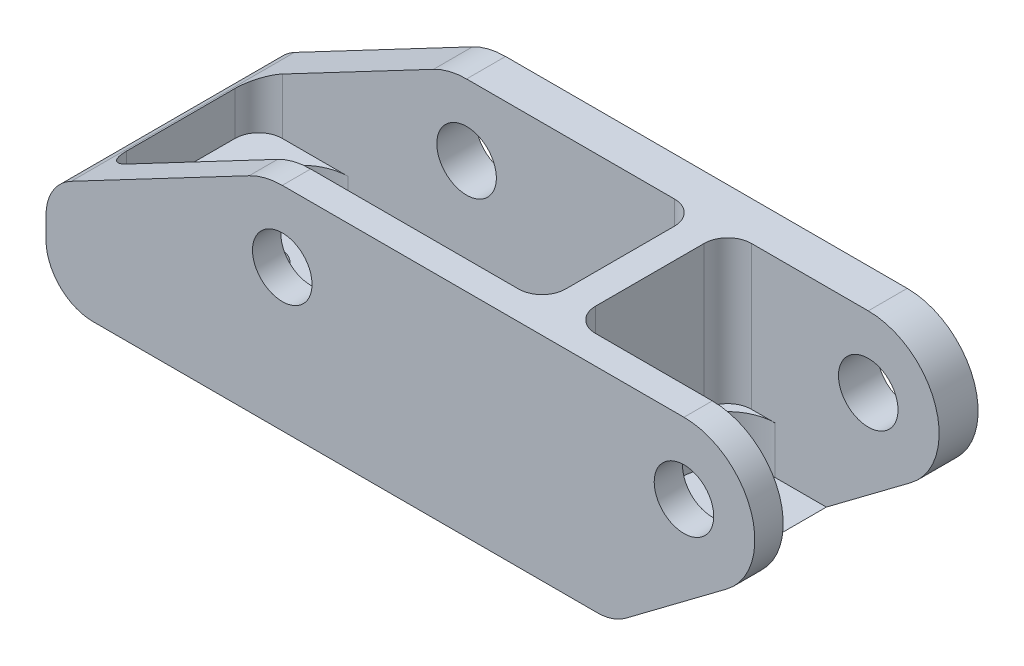
from build123d import *

# Parameters (mm, degrees)
SKETCH1_R           = 3.149606299
BOSS_EXTRUDE1_DEPTH = 28.575
CUT_EXTRUDE1_DEPTH  = 19.304
CUT_EXTRUDE7_DEPTH  = 6.35
SKETCH5_R           = 4
CUT_EXTRUDE3_DEPTH  = 31


with BuildPart() as part:
    # Sketch1 → Boss-Extrude1 (new body)
    with BuildSketch(Plane(origin=(0, 0, 0), x_dir=(1, 0, 0), z_dir=(0, 1, 0))):
        Polygon((0, 6.666666667), (0, 23.333333333), (0, 30), (6.666666667, 30), (93.333333333, 30), (100, 30), (100, 0), (93.333333333, 0), (6.666666667, 0), (0, 0), align=None)
        with Locations((13.333333333, 15)):
            Circle(SKETCH1_R, mode=Mode.SUBTRACT)
        with Locations((53.333333333, 15)):
            Circle(SKETCH1_R, mode=Mode.SUBTRACT)
    extrude(amount=-BOSS_EXTRUDE1_DEPTH)

    # Sketch2 → Cut-Extrude1 (cut)
    with BuildSketch(Plane(origin=(0, 0, 0), x_dir=(1, 0, 0), z_dir=(0, 1, 0))):
        with BuildLine():
            Line((3.810000003, 6.985), (3.810000003, 21.59))
            ThreePointArc((3.810000003, 21.59), (4.739935973, 23.83506403), (6.985000003, 24.765))
            Line((6.985000003, 24.765), (59.678333333, 24.765))
            ThreePointArc((59.678333333, 24.765), (61.923397364, 23.83506403), (62.853333333, 21.59))
            Line((62.853333333, 21.59), (62.853333333, 6.985))
            ThreePointArc((62.853333333, 6.985), (61.923397364, 4.73993597), (59.678333333, 3.81))
            Line((59.678333333, 3.81), (6.985000003, 3.81))
            ThreePointArc((6.985000003, 3.81), (4.739935973, 4.73993597), (3.810000003, 6.985))
        make_face()
        with BuildLine():
            Line((66.853333333, 6.985), (66.853333333, 21.59))
            ThreePointArc((66.853333333, 21.59), (67.783269303, 23.83506403), (70.028333333, 24.765))
            Line((70.028333333, 24.765), (95.25, 24.765))
            Line((95.25, 24.765), (95.25, 3.81))
            Line((95.25, 3.81), (70.028333333, 3.81))
            ThreePointArc((70.028333333, 3.81), (67.783269303, 4.73993597), (66.853333333, 6.985))
        make_face()
    extrude(amount=-CUT_EXTRUDE1_DEPTH, mode=Mode.SUBTRACT)

    # Sketch9 → Cut-Extrude7 (cut)
    with BuildSketch(Plane(origin=(0, -19.304, 0), x_dir=(1, 0, 0), z_dir=(0, 1, 0))):
        with BuildLine():
            Line((7.649092718, 18.135984848), (10.793997252, 22.263484848))
            ThreePointArc((10.793997252, 22.263484848), (13.026694001, 24.105359338), (15.844904534, 24.765))
            Line((15.844904534, 24.765), (50.818428803, 24.765))
            ThreePointArc((50.818428803, 24.765), (53.636639335, 24.105359338), (55.869336085, 22.263484848))
            Line((55.869336085, 22.263484848), (59.014240619, 18.135984848))
            ThreePointArc((59.014240619, 18.135984848), (60.313333337, 14.2875), (59.014240619, 10.439015152))
            Line((59.014240619, 10.439015152), (55.869336085, 6.311515152))
            ThreePointArc((55.869336085, 6.311515152), (53.636639335, 4.469640662), (50.818428803, 3.81))
            Line((50.818428803, 3.81), (15.844904534, 3.81))
            ThreePointArc((15.844904534, 3.81), (13.026694001, 4.469640662), (10.793997252, 6.311515152))
            Line((10.793997252, 6.311515152), (7.649092718, 10.439015152))
            ThreePointArc((7.649092718, 10.439015152), (6.35, 14.2875), (7.649092718, 18.135984848))
        make_face()
        with BuildLine():
            Line((66.853333333, 18.415), (66.853333333, 10.16))
            ThreePointArc((66.853333333, 10.16), (68.713205273, 5.669871939), (73.203333333, 3.81))
            Line((73.203333333, 3.81), (95.25, 3.81))
            Line((95.25, 3.81), (95.25, 24.765))
            Line((95.25, 24.765), (73.203333333, 24.765))
            ThreePointArc((73.203333333, 24.765), (68.713205273, 22.905128061), (66.853333333, 18.415))
        make_face()
    extrude(amount=-CUT_EXTRUDE7_DEPTH, mode=Mode.SUBTRACT)

    # Sketch5 → Cut-Extrude3 (cut, through all)
    with BuildSketch(Plane(origin=(0, 0, -30), x_dir=(-1, 0, 0), z_dir=(0, 0, -1))):
        with BuildLine():
            Line((0, 0), (-31.75, 0))
            ThreePointArc((-31.75, 0), (-29.462234044, -0.278825011), (-27.308407483, -1.098975973))
            Line((-27.308407483, -1.098975973), (-3.388938322, -13.707595992))
            ThreePointArc((-3.388938322, -13.707595992), (-0.912848096, -16.044719868), (0, -19.324945344))
            Line((0, -19.324945344), (0, 0))
        make_face()
        with BuildLine():
            ThreePointArc((0, -22.225), (-1.859871939, -26.715128061), (-6.35, -28.575))
            Line((-6.35, -28.575), (0, -28.575))
            Line((0, -28.575), (0, -22.225))
        make_face()
        with BuildLine():
            Line((-77.893333333, -27.305), (-91.44, -17.145))
            ThreePointArc((-91.44, -17.145), (-94.761208414, -6.512930529), (-85.725, 0))
            Line((-85.725, 0), (-100, 0))
            Line((-100, 0), (-100, -28.575))
            Line((-100, -28.575), (-74.083333333, -28.575))
            ThreePointArc((-74.083333333, -28.575), (-76.091379648, -28.249138943), (-77.893333333, -27.305))
        make_face()
        with Locations((-85.725, -9.525)):
            Circle(SKETCH5_R)
        with Locations((-31.75, -9.525)):
            Circle(SKETCH5_R)
    extrude(amount=-CUT_EXTRUDE3_DEPTH, mode=Mode.SUBTRACT)


solid = part.part
